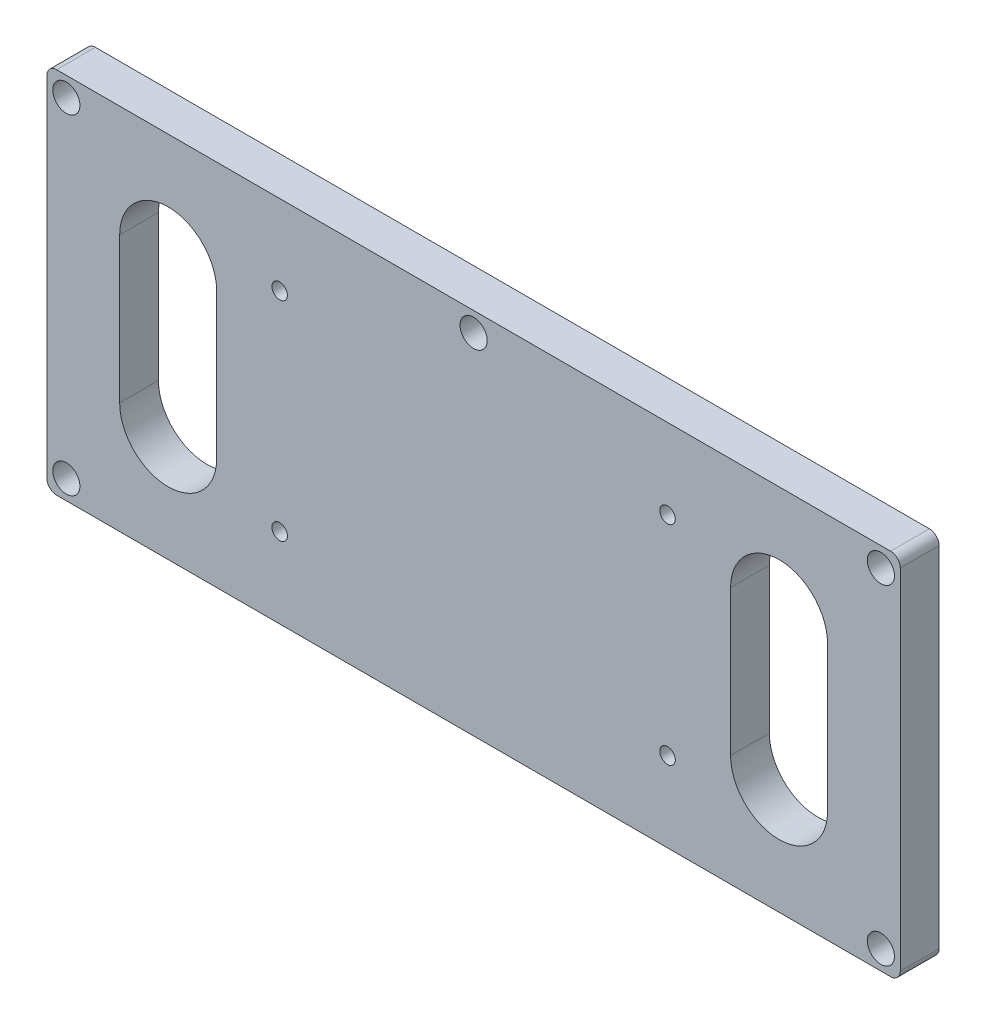
from build123d import *

# Parameters (mm, degrees)
SKETCH_1_W          = 176
SKETCH_1_H          = 76
EXTRUDE_1_DEPTH     = 8
SKETCH_2_R          = 1.6
CUT_EXTRUDE_1_DEPTH = 97.187317251
SKETCH_2_3_R        = 2.6
CUT_EXTRUDE_2_DEPTH = 3
SKETCH_4_R          = 2.8
CUT_EXTRUDE_3_DEPTH = 4
FILLET_1_R          = 2
SKETCH1_R           = 1.6
CUT_EXTRUDE1_DEPTH  = 97.187317251
SKETCH2_R           = 3
CUT_EXTRUDE2_DEPTH  = 4
CUT_EXTRUDE3_DEPTH  = 97.187317251


with BuildPart() as part:
    # 草图1 → 凸台-拉伸1 (new body)
    with BuildSketch(Plane.XY):
        Rectangle(SKETCH_1_W, SKETCH_1_H)
    extrude(amount=EXTRUDE_1_DEPTH)

    # 草图2 → 切除-拉伸1 (cut, through all)
    with BuildSketch(Plane(origin=(0, 0, 0), x_dir=(-1, 0, 0), z_dir=(0, 0, -1))):
        with Locations((-84, 34)):
            Circle(SKETCH_2_R)
        with Locations((-84, -34)):
            Circle(SKETCH_2_R)
        with Locations((0, 34)):
            Circle(SKETCH_2_R)
        with Locations((84, 34)):
            Circle(SKETCH_2_R)
        with Locations((84, -34)):
            Circle(SKETCH_2_R)
    extrude(amount=-CUT_EXTRUDE_1_DEPTH, mode=Mode.SUBTRACT)

    # 草图2<3> → 切除-拉伸2 (cut)
    with BuildSketch(Plane(origin=(0, 0, 0), x_dir=(-1, 0, 0), z_dir=(0, 0, -1))):
        with Locations((-84, 0)):
            Circle(SKETCH_2_3_R)
        with Locations((84, 0)):
            Circle(SKETCH_2_3_R)
        with Locations((0, -34)):
            Circle(SKETCH_2_3_R)
    extrude(amount=-CUT_EXTRUDE_2_DEPTH, mode=Mode.SUBTRACT)

    # 草图4 → 切除-拉伸3 (cut)
    with BuildSketch(Plane.XY.offset(8)):
        with Locations((-84, 34)):
            Circle(SKETCH_4_R)
        with Locations((0, 34)):
            Circle(SKETCH_4_R)
        with Locations((-84, -34)):
            Circle(SKETCH_4_R)
        with Locations((84, 34)):
            Circle(SKETCH_4_R)
        with Locations((84, -34)):
            Circle(SKETCH_4_R)
    extrude(amount=-CUT_EXTRUDE_3_DEPTH, mode=Mode.SUBTRACT)

    # 圆角1
    fillet_1_edges = [part.edges().sort_by_distance(p)[0] for p in [
        (88, 38, 4),
        (88, -38, 4),
        (-88, -38, 4),
        (-88, 38, 4),
    ]]
    fillet(fillet_1_edges, radius=FILLET_1_R)

    # Sketch1 → Cut-Extrude1 (cut, through all)
    with BuildSketch(Plane.XY.offset(8)):
        with Locations((-40, 21.5)):
            Circle(SKETCH1_R)
        with Locations((40, 21.5)):
            Circle(SKETCH1_R)
        with Locations((40, -21.5)):
            Circle(SKETCH1_R)
        with Locations((-40, -21.5)):
            Circle(SKETCH1_R)
    extrude(amount=-CUT_EXTRUDE1_DEPTH, mode=Mode.SUBTRACT)

    # Sketch2 → Cut-Extrude2 (cut)
    with BuildSketch(Plane(origin=(0, 0, 0), x_dir=(-1, 0, 0), z_dir=(0, 0, -1))):
        with Locations((-40, 21.5)):
            Circle(SKETCH2_R)
        with Locations((40, 21.5)):
            Circle(SKETCH2_R)
        with Locations((40, -21.5)):
            Circle(SKETCH2_R)
        with Locations((-40, -21.5)):
            Circle(SKETCH2_R)
    extrude(amount=-CUT_EXTRUDE2_DEPTH, mode=Mode.SUBTRACT)

    # Sketch3 → Cut-Extrude3 (cut, through all)
    with BuildSketch(Plane.XY.offset(8)):
        with BuildLine():
            Line((-73, -15), (-73, 15))
            ThreePointArc((-73, 15), (-63, 25), (-53, 15))
            Line((-53, 15), (-53, -15))
            ThreePointArc((-53, -15), (-63, -25), (-73, -15))
        make_face()
        with BuildLine():
            Line((73, -15), (73, 15))
            ThreePointArc((73, 15), (63, 25), (53, 15))
            Line((53, 15), (53, -15))
            ThreePointArc((53, -15), (63, -25), (73, -15))
        make_face()
    extrude(amount=-CUT_EXTRUDE3_DEPTH, mode=Mode.SUBTRACT)


solid = part.part
